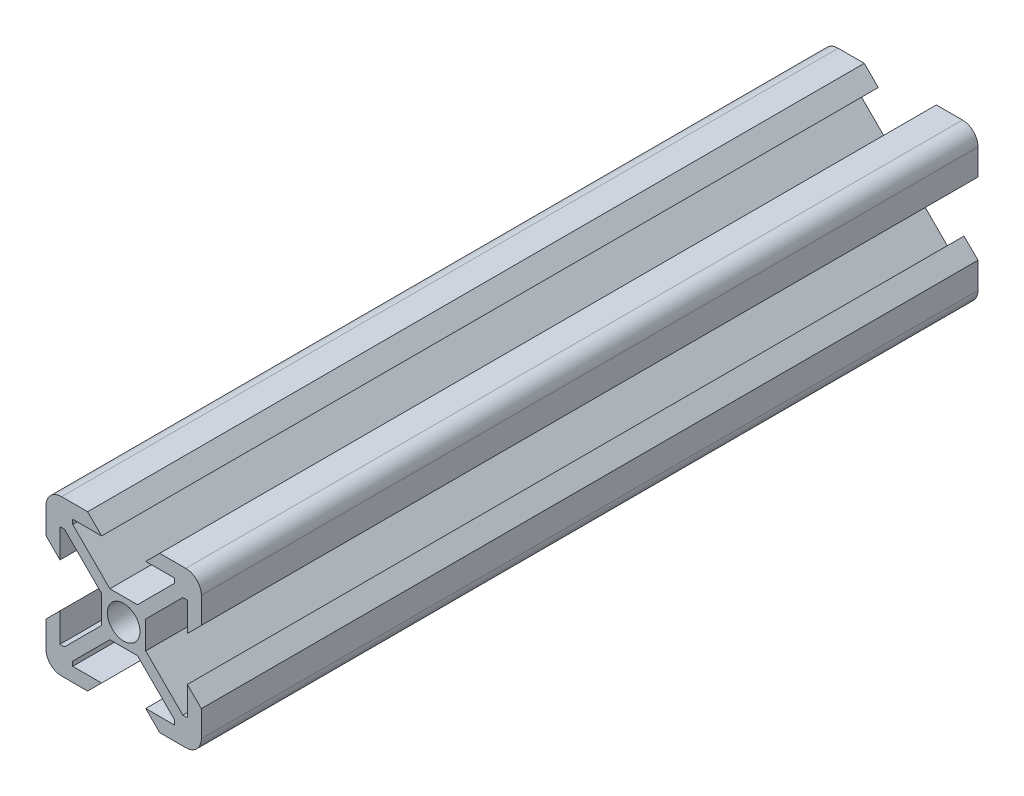
from build123d import *

# Parameters (mm, degrees)
SKETCH1_W           = 5.68
SKETCH1_H           = 5.68
SKETCH1_R           = 2.1
BOSS_EXTRUDE1_DEPTH = 100


with BuildPart() as part:
    # Sketch1 → Boss-Extrude1 (new body)
    with BuildSketch(Plane.XY):
        Rectangle(SKETCH1_W, SKETCH1_H)
        Circle(SKETCH1_R, mode=Mode.SUBTRACT)
        with BuildLine():
            ThreePointArc((-10, 8), (-9.414213562, 9.414213562), (-8, 10))
            Line((-8, 10), (-4.64, 10))
            Line((-4.64, 10), (-2.84, 8.2))
            Line((-2.84, 8.2), (-6.56, 8.2))
            Line((-6.56, 8.2), (-6.56, 6.56))
            Line((-6.56, 6.56), (-8.2, 6.56))
            Line((-8.2, 6.56), (-8.2, 2.84))
            Line((-8.2, 2.84), (-10, 4.64))
            Line((-10, 4.64), (-10, 8))
        make_face()
        with BuildLine():
            Line((10, 4.64), (10, 8))
            ThreePointArc((10, 8), (9.414213562, 9.414213562), (8, 10))
            Line((8, 10), (4.64, 10))
            Line((4.64, 10), (2.84, 8.2))
            Line((2.84, 8.2), (6.56, 8.2))
            Line((6.56, 8.2), (6.56, 6.56))
            Line((6.56, 6.56), (8.2, 6.56))
            Line((8.2, 6.56), (8.2, 2.84))
            Line((8.2, 2.84), (10, 4.64))
        make_face()
        with BuildLine():
            Line((-10, -4.64), (-10, -8))
            ThreePointArc((-10, -8), (-9.414213562, -9.414213562), (-8, -10))
            Line((-8, -10), (-4.64, -10))
            Line((-4.64, -10), (-2.84, -8.2))
            Line((-2.84, -8.2), (-6.56, -8.2))
            Line((-6.56, -8.2), (-6.56, -6.56))
            Line((-6.56, -6.56), (-8.2, -6.56))
            Line((-8.2, -6.56), (-8.2, -2.84))
            Line((-8.2, -2.84), (-10, -4.64))
        make_face()
        with BuildLine():
            Line((4.64, -10), (8, -10))
            ThreePointArc((8, -10), (9.414213562, -9.414213562), (10, -8))
            Line((10, -8), (10, -4.64))
            Line((10, -4.64), (8.2, -2.84))
            Line((8.2, -2.84), (8.2, -6.56))
            Line((8.2, -6.56), (6.56, -6.56))
            Line((6.56, -6.56), (6.56, -8.2))
            Line((6.56, -8.2), (2.84, -8.2))
            Line((2.84, -8.2), (4.64, -10))
        make_face()
        Polygon((7.620660172, -6.56), (2.84, -1.779339828), (2.84, -2.84), (6.56, -6.56), align=None)
        Polygon((6.56, -6.56), (2.84, -2.84), (1.779339828, -2.84), (6.56, -7.620660172), align=None)
        Polygon((-1.779339828, -2.84), (-2.84, -2.84), (-6.56, -6.56), (-6.56, -7.620660172), align=None)
        Polygon((-2.84, -2.84), (-2.84, -1.779339828), (-7.620660172, -6.56), (-6.56, -6.56), align=None)
        Polygon((-2.84, 1.779339828), (-2.84, 2.84), (-6.56, 6.56), (-7.620660172, 6.56), align=None)
        Polygon((-2.84, 2.84), (-1.779339828, 2.84), (-6.56, 7.620660172), (-6.56, 6.56), align=None)
        Polygon((6.56, 6.56), (6.56, 7.620660172), (1.779339828, 2.84), (2.84, 2.84), align=None)
        Polygon((7.620660172, 6.56), (6.56, 6.56), (2.84, 2.84), (2.84, 1.779339828), align=None)
    extrude(amount=BOSS_EXTRUDE1_DEPTH)


solid = part.part
